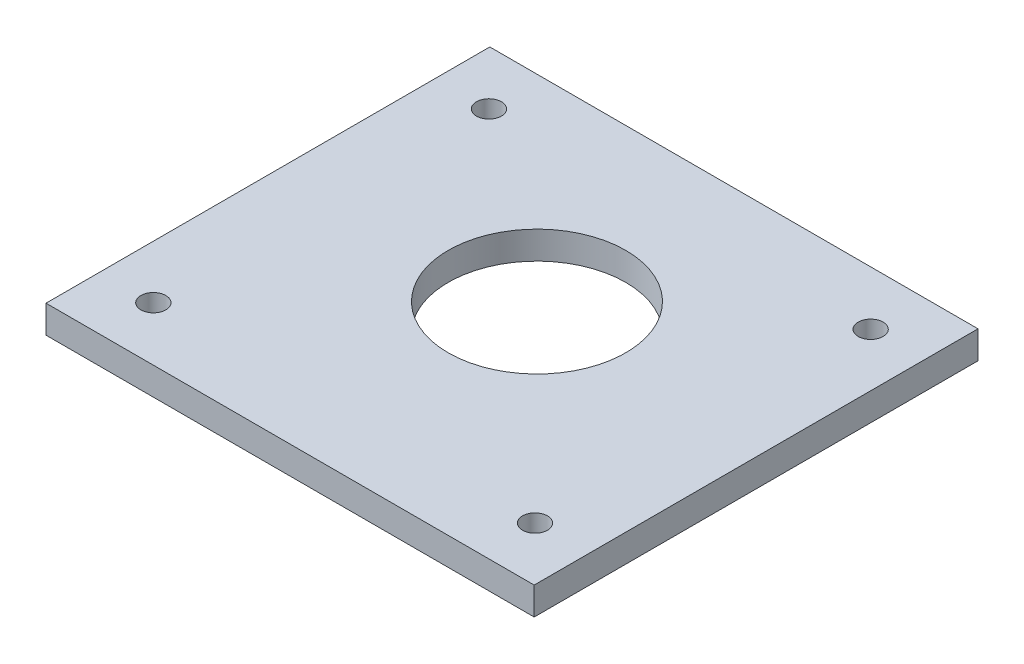
from build123d import *

# Parameters (mm, degrees)
SKETCH_1_W      = 88
SKETCH_1_H      = 80
SKETCH_1_R      = 2.25
SKETCH_1_R_2    = 16
EXTRUDE_1_DEPTH = 5


with BuildPart() as part:
    # Эскиз1 → Бобышка-Вытянуть1 (new body)
    with BuildSketch(Plane(origin=(0, 0, 0), x_dir=(1, 0, 0), z_dir=(0, 1, 0))):
        Rectangle(SKETCH_1_W, SKETCH_1_H)
        with Locations((-34.4, 30.25)):
            Circle(SKETCH_1_R, mode=Mode.SUBTRACT)
        with Locations((34.4, 30.25)):
            Circle(SKETCH_1_R, mode=Mode.SUBTRACT)
        with Locations((34.4, -30.25)):
            Circle(SKETCH_1_R, mode=Mode.SUBTRACT)
        with Locations((-34.4, -30.25)):
            Circle(SKETCH_1_R, mode=Mode.SUBTRACT)
        with Locations((0, 4.5)):
            Circle(SKETCH_1_R_2, mode=Mode.SUBTRACT)
    extrude(amount=EXTRUDE_1_DEPTH)


solid = part.part
